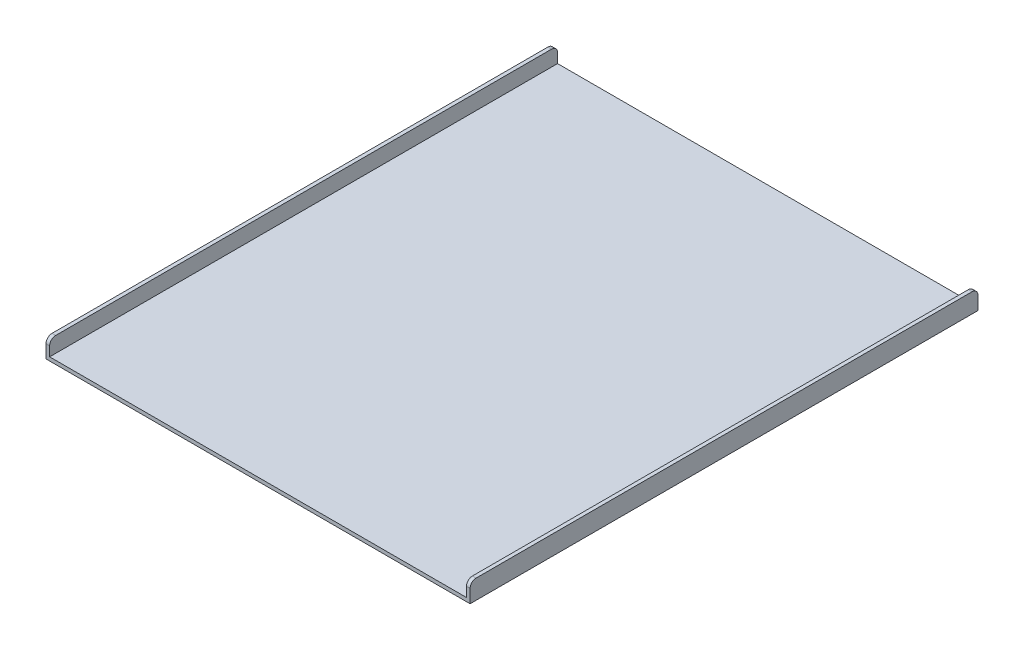
from build123d import *

# Parameters (mm, degrees)
EXTRUDE_THIN1_DEPTH = 421.049210887
FILLET1_R           = 10
SKETCH_2_R          = 19.05
EXTRUDE_1_DEPTH     = 23.24974156
SKETCH_3_R          = 19.05
EXTRUDE_2_DEPTH     = 23


with BuildPart() as part:
    # Sketch1 → Extrude-Thin1 (new body, symmetric)
    with BuildSketch(Plane.XY):
        Polygon((-250.514148937, 25.753634758), (-250.514148937, 0), (440.503291061, 0), (440.503291061, 25.915671281), (446.551474959, 25.915671281), (446.551474959, -6.048183898), (-256.562332835, -6.048183898), (-256.562332835, 25.753634758), align=None)
    extrude(amount=EXTRUDE_THIN1_DEPTH, both=True)

    # Fillet1
    fillet1_edges = [part.edges().sort_by_distance(p)[0] for p in [
        (-253.538240886, 25.753634758, 421.049210887),
        (443.52738301, 25.915671281, 421.049210887),
        (-253.538240886, 25.753634758, -421.049210887),
        (443.52738301, 25.915671281, -421.049210887),
    ]]
    fillet(fillet1_edges, radius=FILLET1_R)

    # 草图2 → 凸台-拉伸1 (add)
    with BuildSketch(Plane(origin=(0, -6.048183898, 0), x_dir=(-1, 0, 0), z_dir=(0, -1, 0))):
        with Locations((-360.164689426, 358.012657815)):
            Circle(SKETCH_2_R)
    extrude(amount=EXTRUDE_1_DEPTH)

    # 草图3 → 凸台-拉伸2 (add)
    with BuildSketch(Plane(origin=(0, -6.048183898, 0), x_dir=(-1, 0, 0), z_dir=(0, -1, 0))):
        with Locations((174.06050089, -351.274172881)):
            Circle(SKETCH_3_R)
    extrude(amount=EXTRUDE_2_DEPTH)


solid = part.part
